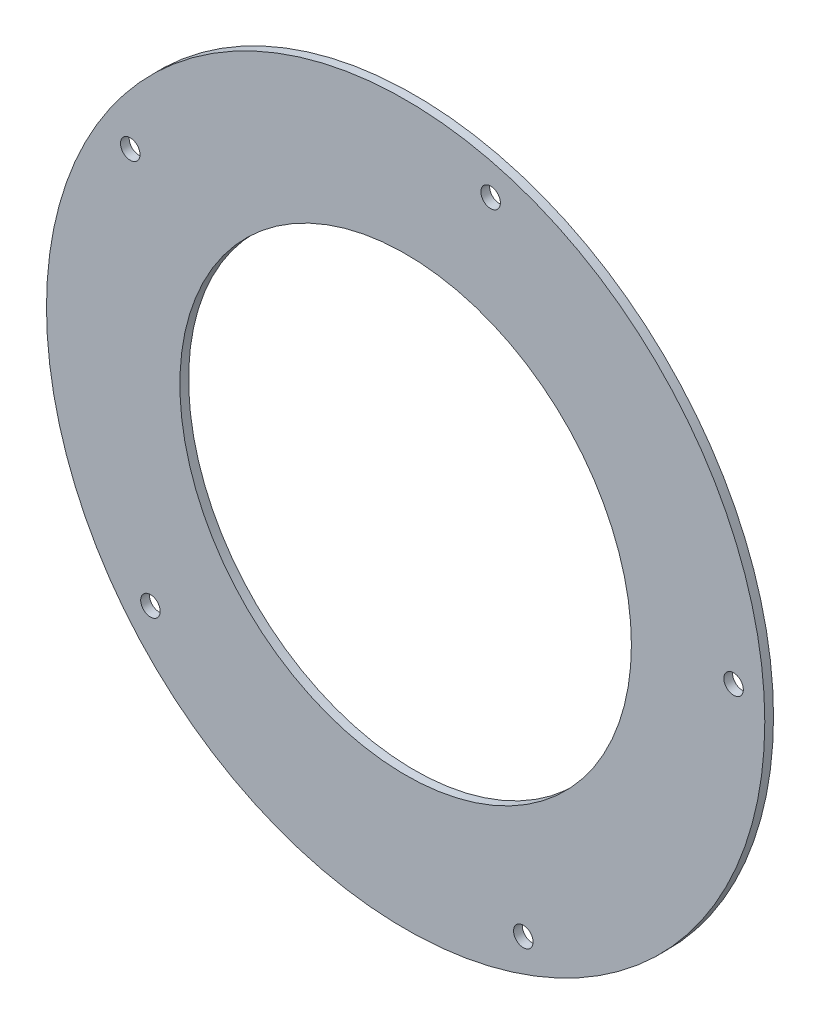
from build123d import *

# Parameters (mm, degrees)
SKETCH1_R           = 35
BOSS_EXTRUDE1_DEPTH = 1.3
SKETCH2_R           = 22
CUT_EXTRUDE1_DEPTH  = 50.514543318
MOVE_FACE1_BY       = 0.7
SKETCH5_R           = 0.95
CUT_EXTRUDE4_DEPTH  = 50.501111099
CIRPATTERN2_COUNT   = 5
MOVE_FACE2_BY       = 0.25


with BuildPart() as part:
    # Sketch1 → Boss-Extrude1 (new body)
    with BuildSketch(Plane.XY):
        Circle(SKETCH1_R)
    extrude(amount=BOSS_EXTRUDE1_DEPTH)

    # Sketch2 → Cut-Extrude1 (cut, through all)
    with BuildSketch(Plane.XY.offset(1.3)):
        Circle(SKETCH2_R)
    extrude(amount=-CUT_EXTRUDE1_DEPTH, mode=Mode.SUBTRACT)

    # Move Face1: a face moved inward by 0.7
    extrude(part.faces().sort_by_distance((0, -28, 0))[0], amount=MOVE_FACE1_BY, dir=(0, 0, 1), mode=Mode.SUBTRACT)

    # Sketch5 → Cut-Extrude4 (cut, through all)
    with BuildSketch(Plane.XY.offset(1.3)):
        with Locations((8.282209443, 30.909626441)):
            Circle(SKETCH5_R)
    cut_extrude4 = extrude(amount=-CUT_EXTRUDE4_DEPTH, mode=Mode.SUBTRACT)

    # CirPattern2: Cut-Extrude4 ×5 about axis
    cirpattern2_axis = Axis((0, 0, -88.99), (0, 0, 1))
    for i in range(1, CIRPATTERN2_COUNT):
        add(cut_extrude4.rotate(cirpattern2_axis, i * 360 / CIRPATTERN2_COUNT), mode=Mode.SUBTRACT)

    # Move Face2: a face moved outward by 0.25
    extrude(part.faces().sort_by_distance((0, -28, 1.3))[0], amount=MOVE_FACE2_BY, dir=(0, 0, 1))


solid = part.part
